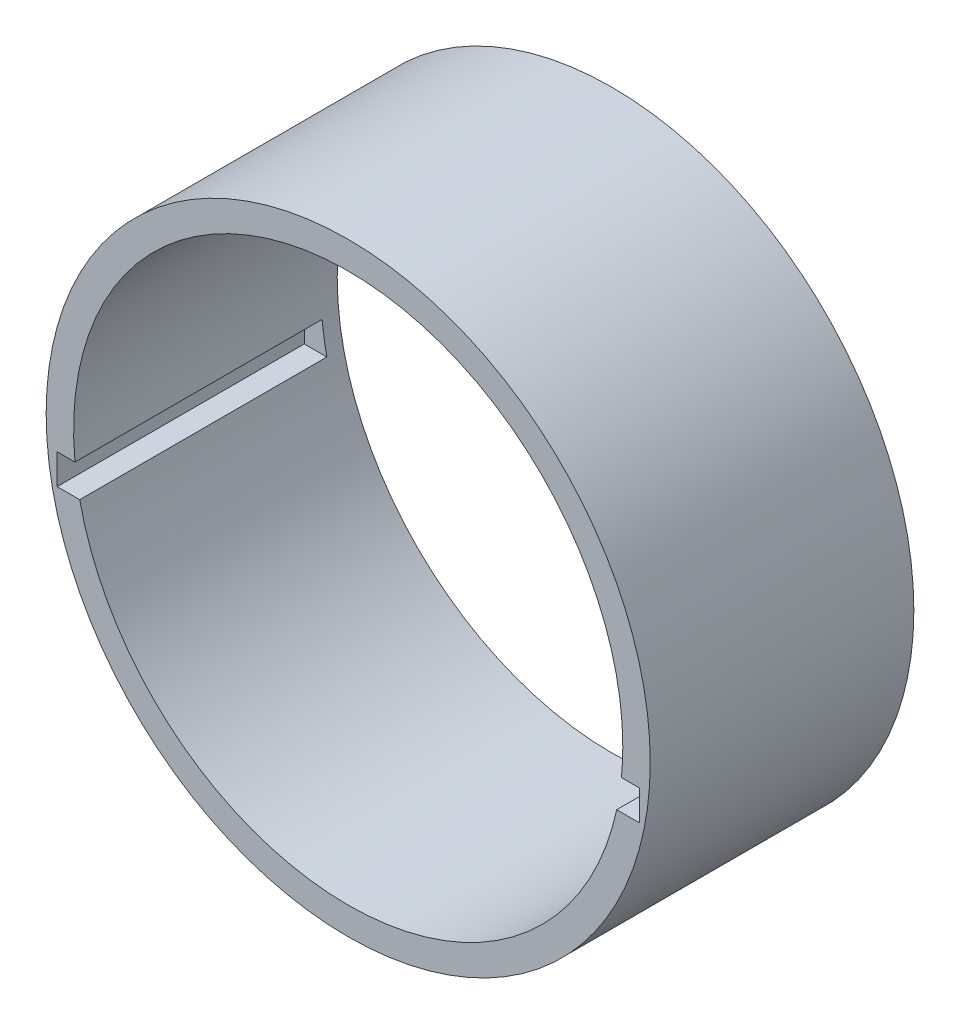
from build123d import *

# Parameters (mm, degrees)
SKETCH1_R           = 55
BOSS_EXTRUDE1_DEPTH = 48
SKETCH2_R           = 50
CUT_EXTRUDE1_DEPTH  = 49
SKETCH5_W           = 106
SKETCH5_H           = 5.5
CUT_EXTRUDE2_DEPTH  = 45


with BuildPart() as part:
    # Sketch1 → Boss-Extrude1 (new body)
    with BuildSketch(Plane.XY):
        Circle(SKETCH1_R)
    extrude(amount=BOSS_EXTRUDE1_DEPTH)

    # Sketch2 → Cut-Extrude1 (cut, through all)
    with BuildSketch(Plane.XY.offset(48)):
        Circle(SKETCH2_R)
    extrude(amount=-CUT_EXTRUDE1_DEPTH, mode=Mode.SUBTRACT)

    # Sketch5 → Cut-Extrude2 (cut)
    with BuildSketch(Plane.XY.offset(48)):
        with Locations((0, -7.75)):
            Rectangle(SKETCH5_W, SKETCH5_H)
    extrude(amount=-CUT_EXTRUDE2_DEPTH, mode=Mode.SUBTRACT)


solid = part.part
